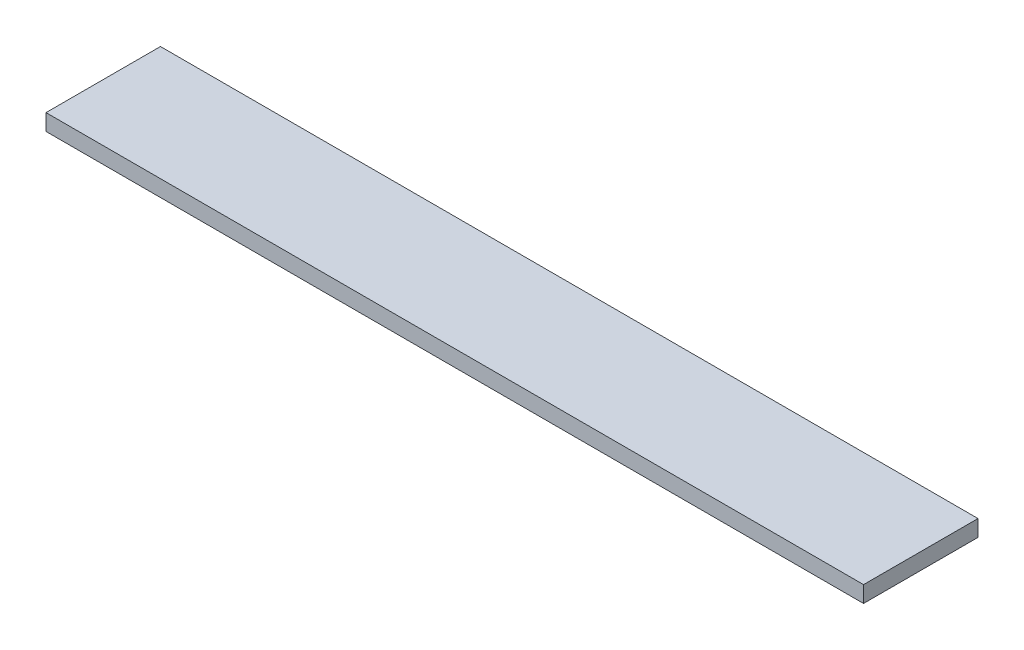
from build123d import *

# Parameters (mm, degrees)
SKETCH1_W           = 500
SKETCH1_H           = 70
BOSS_EXTRUDE1_DEPTH = 10


with BuildPart() as part:
    # Sketch1 → Boss-Extrude1 (new body)
    with BuildSketch(Plane(origin=(0, 0, 0), x_dir=(1, 0, 0), z_dir=(0, 1, 0))):
        Rectangle(SKETCH1_W, SKETCH1_H)
    extrude(amount=BOSS_EXTRUDE1_DEPTH)


solid = part.part
